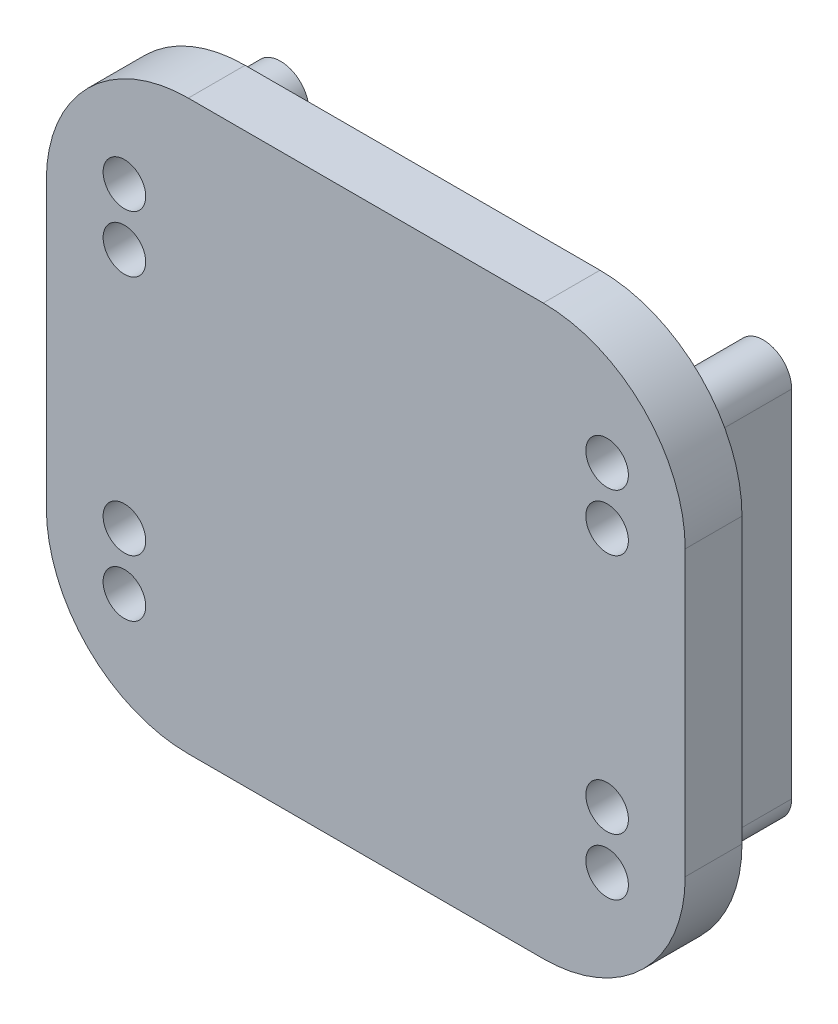
from build123d import *

# Parameters (mm, degrees)
BOSS_EXTRUDE1_DEPTH   = 7
BOSS_EXTRUDE1_2_DEPTH = 7
SKETCH2_W             = 45
SKETCH2_H             = 40
BOSS_EXTRUDE2_DEPTH   = 4
FILLET1_R             = 10
SKETCH3_R             = 1.5
CUT_EXTRUDE1_DEPTH    = 16


with BuildPart() as part:
    # Sketch1 → Boss-Extrude1 (new body)
    with BuildSketch(Plane.XY):
        with BuildLine():
            Line((0, 0), (0, 25))
            ThreePointArc((0, 25), (-2, 27), (-4, 25))
            Line((-4, 25), (-4, 0))
            ThreePointArc((-4, 0), (-2, -2), (0, 0))
        make_face()
    extrude(amount=BOSS_EXTRUDE1_DEPTH)



with BuildPart() as body_2:
    # Sketch1 → Boss-Extrude1 2 (new body)
    with BuildSketch(Plane.XY):
        with BuildLine():
            Line((30, 0), (30, 25))
            ThreePointArc((30, 25), (32, 27), (34, 25))
            Line((34, 25), (34, 0))
            ThreePointArc((34, 0), (32, -2), (30, 0))
        make_face()
    extrude(amount=BOSS_EXTRUDE1_2_DEPTH)


with BuildPart() as part_1:
    add(part.part)

    add(body_2.part)  # Boss-Extrude2 merges body 2
    # Sketch2 → Boss-Extrude2 (add)
    with BuildSketch(Plane.XY.offset(7)):
        with Locations((15, 12.5)):
            Rectangle(SKETCH2_W, SKETCH2_H)
    extrude(amount=BOSS_EXTRUDE2_DEPTH)

    # Fillet1
    fillet1_edges = [part_1.edges().sort_by_distance(p)[0] for p in [
        (37.5, -7.5, 9),
        (37.5, 32.5, 9),
        (-7.5, 32.5, 9),
        (-7.5, -7.5, 9),
    ]]
    fillet(fillet1_edges, radius=FILLET1_R)

    # Sketch3 → Cut-Extrude1 (cut)
    with BuildSketch(Plane(origin=(0, 0, 0), x_dir=(-1, 0, 0), z_dir=(0, 0, -1))):
        with Locations((-32, 0)):
            Circle(SKETCH3_R)
        with Locations((-32, 4)):
            Circle(SKETCH3_R)
        with Locations((2, 0)):
            Circle(SKETCH3_R)
        with Locations((2, 4)):
            Circle(SKETCH3_R)
        with Locations((-32, 25)):
            Circle(SKETCH3_R)
        with Locations((-32, 21)):
            Circle(SKETCH3_R)
        with Locations((2, 25)):
            Circle(SKETCH3_R)
        with Locations((2, 21)):
            Circle(SKETCH3_R)
    extrude(amount=-CUT_EXTRUDE1_DEPTH, mode=Mode.SUBTRACT)


solid = part_1.part
